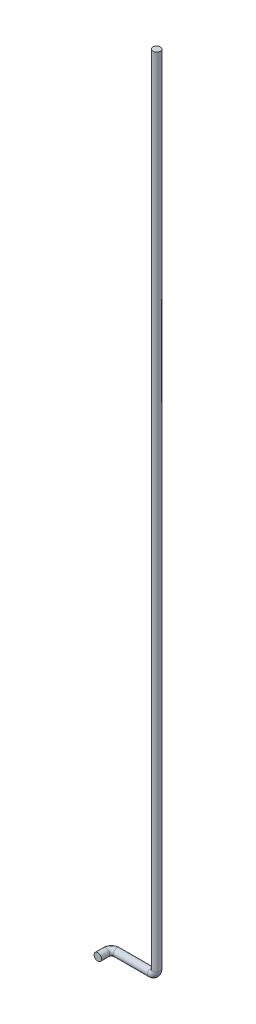
from build123d import *

# Parameters (mm, degrees)
CROQUIS1_R = 13.7


with BuildPart() as part:
    # Barrer1: sweep along a curve in space
    with BuildLine() as barrer1_path:
        Line((0, 0, 0), (0, -2925, 0))
        ThreePointArc((0, -2925, 0), (-5.857864376, -2939.142135624, 0), (-20, -2945, 0))
        Line((-20, -2945, 0), (-146, -2945, 0))
        ThreePointArc((-146, -2945, 0), (-160.142135624, -2945, 5.857864376), (-166, -2945, 20))
        Line((-166, -2945, 20), (-166, -2945, 50))
    # Croquis1 → Barrer1 (sweep)
    with BuildSketch(Plane(origin=(0, 0, 0), x_dir=(1, 0, 0), z_dir=(0, 1, 0))):
        Circle(CROQUIS1_R)
    sweep(path=barrer1_path.line)


solid = part.part
